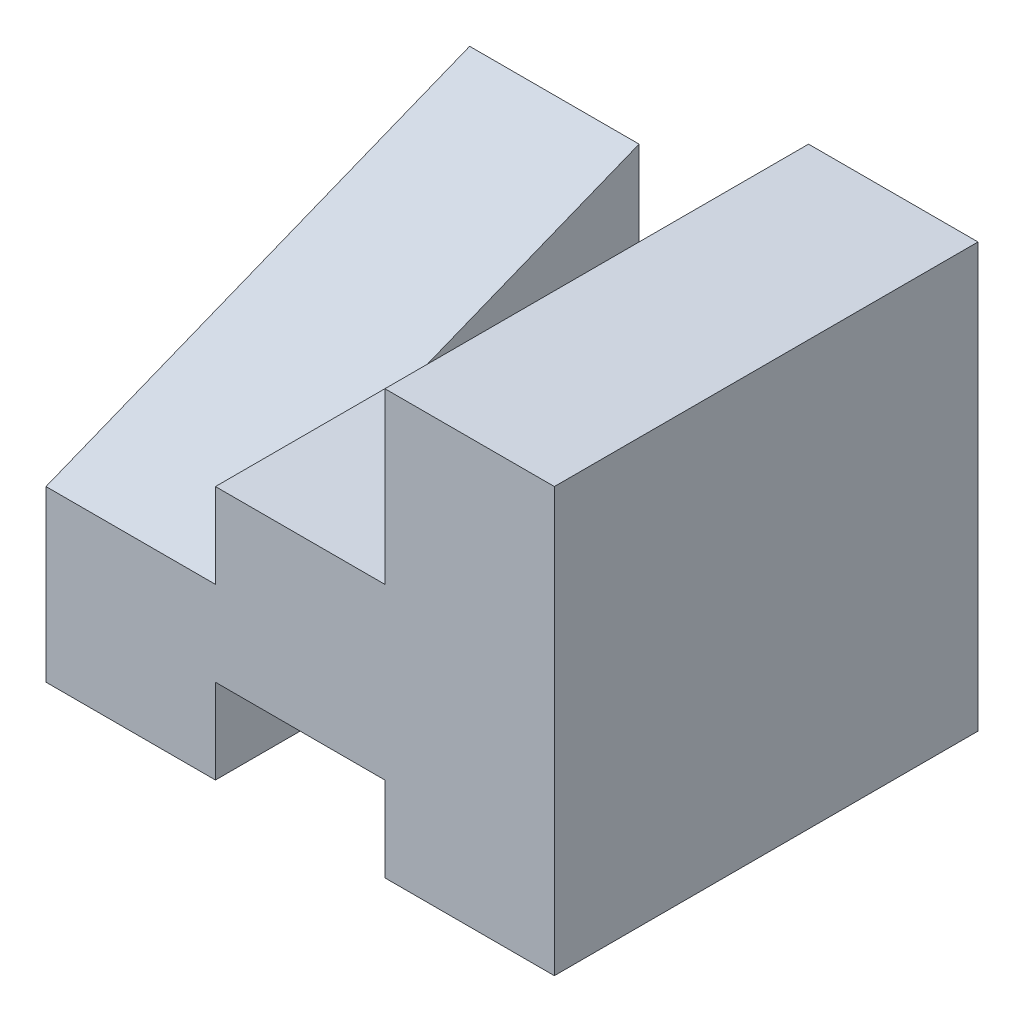
from build123d import *

# Parameters (mm, degrees)
BOSS_EXTRUDE1_DEPTH = 25
BOSS_EXTRUDE2_DEPTH = 10


with BuildPart() as part:
    # Sketch1 → Boss-Extrude1 (new body)
    with BuildSketch(Plane.XY):
        Polygon((-30, 10), (-20, 10), (-20, 15), (-10, 15), (-10, 25), (0, 25), (0, 0), (-10, 0), (-10, 5), (-20, 5), (-20, 0), (-30, 0), align=None)
    extrude(amount=BOSS_EXTRUDE1_DEPTH)

    # Sketch2 → Boss-Extrude2 (add)
    with BuildSketch(Plane.ZY.offset(20)):
        Polygon((0, 10), (0, 20), (25, 10), align=None)
    extrude(amount=BOSS_EXTRUDE2_DEPTH)


solid = part.part
